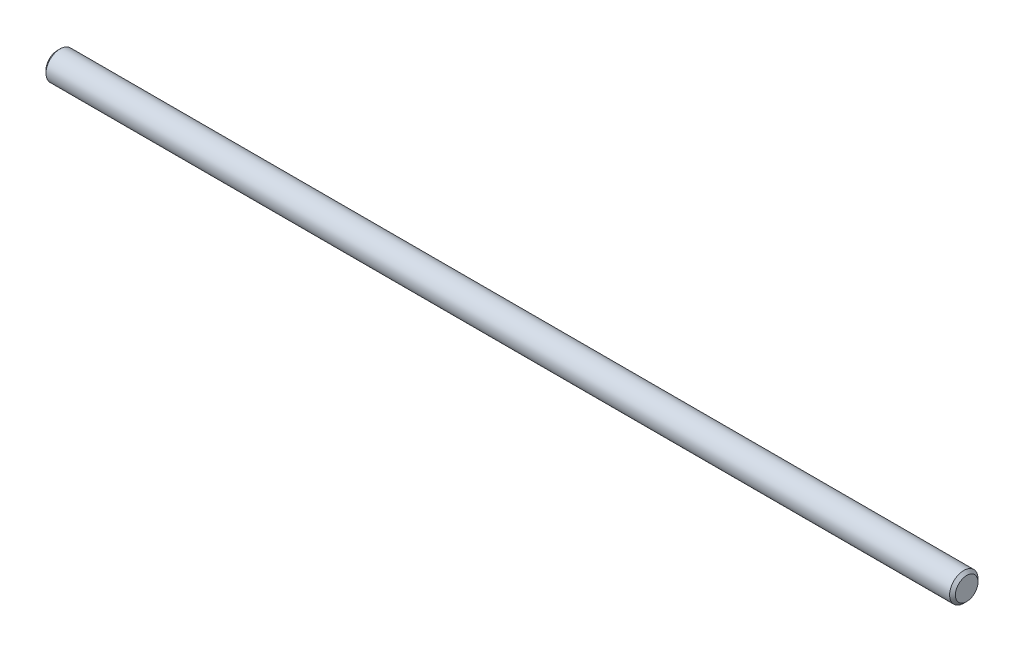
from build123d import *


with BuildPart() as part:
    # Sketch1 → Revolve1 (revolve)
    with BuildSketch(Plane.XY):
        Polygon((-48, 0), (-48, 1.1935), (-47.6935, 1.5), (47.6935, 1.5), (48, 1.1935), (48, 0), align=None)
    revolve(axis=Axis((48, 0, 0), (-1, 0, 0)))


solid = part.part
